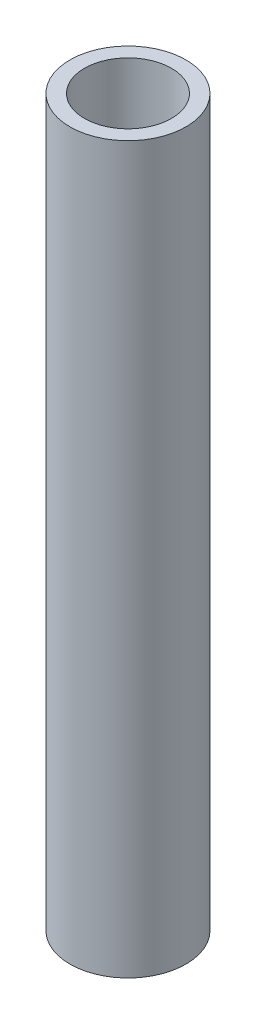
from build123d import *

# Parameters (mm, degrees)
SKETCH_2_R          = 20
EXTRUDE_1_DEPTH     = 250
SKETCH_3_R          = 15
CUT_EXTRUDE_1_DEPTH = 250


with BuildPart() as part:
    # 草圖2 → 填料-伸長1 (new body)
    with BuildSketch(Plane(origin=(0, 0, 0), x_dir=(1, 0, 0), z_dir=(0, 1, 0))):
        Circle(SKETCH_2_R)
    extrude(amount=EXTRUDE_1_DEPTH)

    # 草圖3 → 除料-伸長1 (cut)
    with BuildSketch(Plane.XZ):
        Circle(SKETCH_3_R)
    extrude(amount=-CUT_EXTRUDE_1_DEPTH, mode=Mode.SUBTRACT)


solid = part.part
